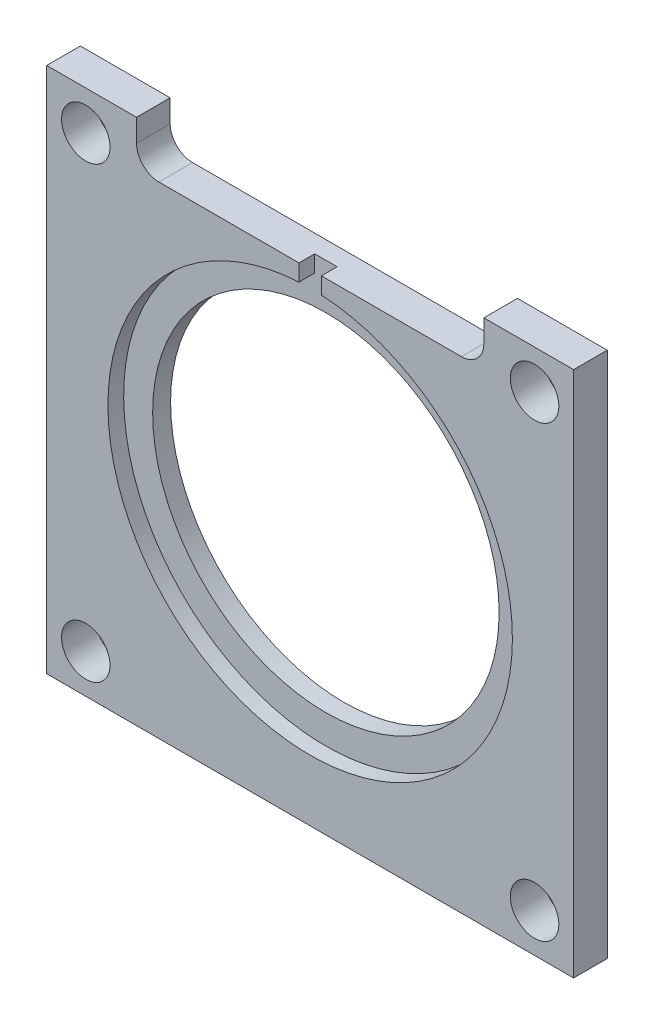
from build123d import *

# Parameters (mm, degrees)
BOSS_EXTRUDE1_DEPTH            = 1.5875
BOSS_EXTRUDE1_DEPTH_BACK       = 1.5875
SKETCH1_W                      = 74.549
SKETCH1_H                      = 74.549
SKETCH1_R                      = 24.511
SKETCH15_W                     = 74.549
SKETCH15_H                     = 74.549
SKETCH15_R                     = 28.6131
BOSS_EXTRUDE11_DEPTH           = 1.5875
SKETCH2_R                      = 3.429
CUT_EXTRUDE1_DEPTH             = 53.809632885
MIRROR2_COPY_1_SKETCH_R        = 3.429
MIRROR2_COPY_1_DEPTH           = 53.809632885
MIRROR2_COPY_2_SKETCH_R        = 3.429
MIRROR2_COPY_2_DEPTH           = 53.809632885
CUT_EXTRUDE6_DEPTH             = 53.809632885
CUT_EXTRUDE6_DEPTH_BACK        = 53.809632885
SKETCH14_W                     = 49.149
SKETCH14_H                     = 8.290530285
FILLET2_R                      = 3.175
CUT_EXTRUDE8_REACH             = 54.81
CUT_EXTRUDE8_DIRECTION_2_DEPTH = 0.635
CUT_EXTRUDE9_START             = -0.635
SKETCH18_R                     = 28.6131
CUT_EXTRUDE9_DEPTH             = 0.635


with BuildPart() as part:
    # Sketch1 → Boss-Extrude1 (new, two sides: drawn at the far end of the back side and taken through both)
    with BuildSketch(Plane.XY.offset(-BOSS_EXTRUDE1_DEPTH_BACK)):
        Rectangle(SKETCH1_W, SKETCH1_H)
        Circle(SKETCH1_R, mode=Mode.SUBTRACT)
    extrude(amount=BOSS_EXTRUDE1_DEPTH + BOSS_EXTRUDE1_DEPTH_BACK)

    # Sketch15 → Boss-Extrude11 (add)
    with BuildSketch(Plane.XY.offset(1.5875)):
        Rectangle(SKETCH15_W, SKETCH15_H)
        Circle(SKETCH15_R, mode=Mode.SUBTRACT)
    extrude(amount=BOSS_EXTRUDE11_DEPTH)

    # Sketch2 → Cut-Extrude1 (cut, symmetric)
    with BuildSketch(Plane.XY.offset(1.5875)):
        with Locations((-31.75, 31.75)):
            Circle(SKETCH2_R)
    cut_extrude1 = extrude(amount=CUT_EXTRUDE1_DEPTH, both=True, mode=Mode.SUBTRACT)

    # Mirror1: Cut-Extrude1 across plane
    add(cut_extrude1.mirror(Plane(origin=(0, 0, 0), x_dir=(0, 0, 1), z_dir=(1, 0, 0))), mode=Mode.SUBTRACT)

    # Mirror2 copy 1 sketch → Mirror2 copy 1 (cut, symmetric)
    with BuildSketch(Plane(origin=(0, 0, 1.5875), x_dir=(-1, 0, 0), z_dir=(0, 0, 1))):
        with Locations((-31.75, 31.75)):
            Circle(MIRROR2_COPY_1_SKETCH_R)
    extrude(amount=MIRROR2_COPY_1_DEPTH, both=True, mode=Mode.SUBTRACT)

    # Mirror2 copy 2 sketch → Mirror2 copy 2 (cut, symmetric)
    with BuildSketch(Plane.XY.offset(1.5875)):
        with Locations((-31.75, -31.75)):
            Circle(MIRROR2_COPY_2_SKETCH_R)
    extrude(amount=MIRROR2_COPY_2_DEPTH, both=True, mode=Mode.SUBTRACT)

    # Sketch14 → Cut-Extrude6 (cut, two sides: drawn at the far end of the back side and taken through both)
    with BuildSketch(Plane.XY.offset(1.5875).offset(-CUT_EXTRUDE6_DEPTH_BACK)):
        with Locations((0, 35.069765143)):
            Rectangle(SKETCH14_W, SKETCH14_H)
    extrude(amount=CUT_EXTRUDE6_DEPTH + CUT_EXTRUDE6_DEPTH_BACK, mode=Mode.SUBTRACT)

    # Fillet2
    fillet2_edges = [part.edges().sort_by_distance(p)[0] for p in [
        (-24.5745, 30.9245, 0.79375),
        (24.5745, 30.9245, 0.79375),
    ]]
    fillet(fillet2_edges, radius=FILLET2_R)

    # Sketch17 → Cut-Extrude8 (cut, up to next)
    with BuildSketch(Plane.XY.offset(1.5875), mode=Mode.PRIVATE) as cut_extrude8_sk1:
        with BuildLine():
            Line((-1.5875, 24.754637718), (-1.5875, 33.858616052))
            ThreePointArc((-1.5875, 33.858616052), (0, 35.446116052), (1.5875, 33.858616052))
            Line((1.5875, 33.858616052), (1.5875, 24.754637718))
            ThreePointArc((1.5875, 24.754637718), (0, 23.167137718), (-1.5875, 24.754637718))
        make_face()
    cut_extrude8_tool1 = extrude(cut_extrude8_sk1.sketch, amount=CUT_EXTRUDE8_REACH, mode=Mode.PRIVATE) & part.part
    add(cut_extrude8_tool1.solids().sort_by_distance((0, 29.306627, 1.5875))[0], mode=Mode.SUBTRACT)

    # Sketch17 → Cut-Extrude8 direction 2 (cut)
    with BuildSketch(Plane.XY.offset(1.5875)):
        with BuildLine():
            Line((-1.5875, 24.754637718), (-1.5875, 33.858616052))
            ThreePointArc((-1.5875, 33.858616052), (0, 35.446116052), (1.5875, 33.858616052))
            Line((1.5875, 33.858616052), (1.5875, 24.754637718))
            ThreePointArc((1.5875, 24.754637718), (0, 23.167137718), (-1.5875, 24.754637718))
        make_face()
    extrude(amount=-CUT_EXTRUDE8_DIRECTION_2_DEPTH, mode=Mode.SUBTRACT)

    # Sketch18 → Cut-Extrude9 (cut)
    with BuildSketch(Plane.XY.offset(1.5875).offset(CUT_EXTRUDE9_START)):
        Circle(SKETCH18_R)
    extrude(amount=CUT_EXTRUDE9_DEPTH, mode=Mode.SUBTRACT)


solid = part.part
